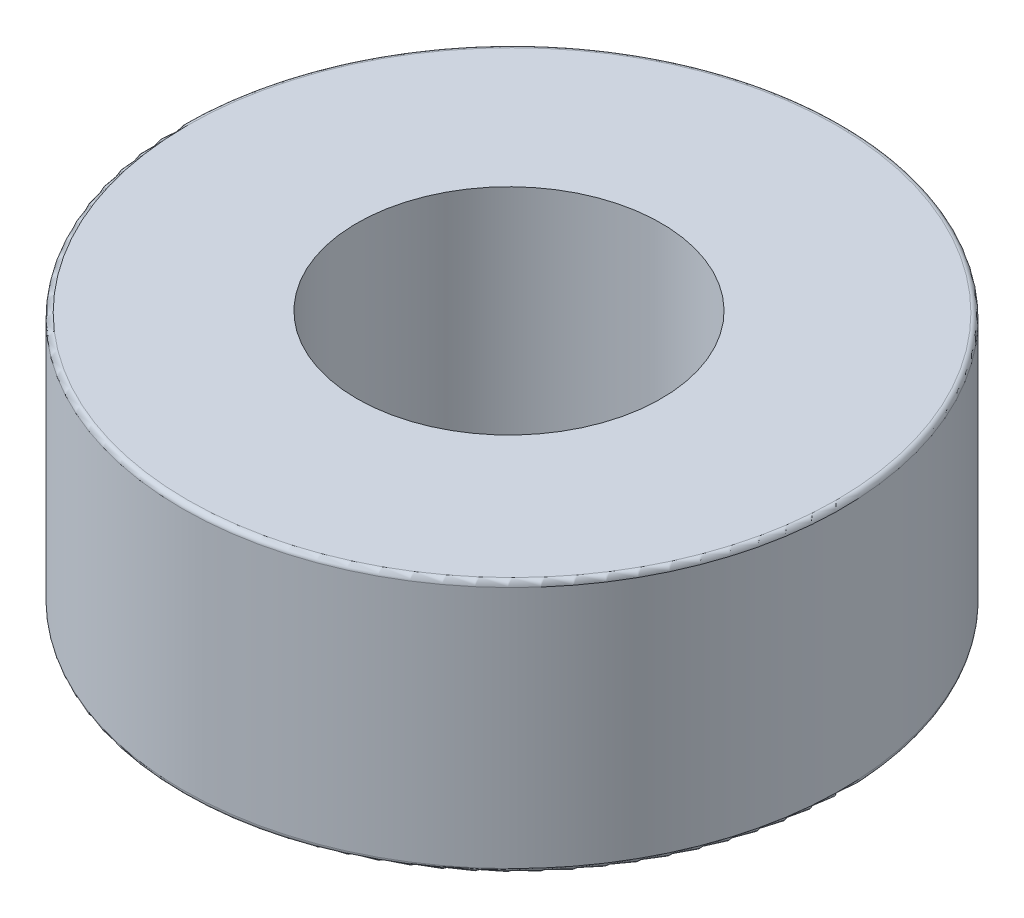
from build123d import *

# Parameters (mm, degrees)
SKETCH1_R           = 6.5
SKETCH1_R_2         = 3
BOSS_EXTRUDE1_DEPTH = 5
FILLET1_R           = 0.1


with BuildPart() as part:
    # Sketch1 → Boss-Extrude1 (new body)
    with BuildSketch(Plane(origin=(0, 0, 0), x_dir=(1, 0, 0), z_dir=(0, 1, 0))):
        with Locations((0.059793137, 0)):
            Circle(SKETCH1_R)
        Circle(SKETCH1_R_2, mode=Mode.SUBTRACT)
    extrude(amount=BOSS_EXTRUDE1_DEPTH)

    # Fillet1
    fillet1_edges = [part.edges().sort_by_distance(p)[0] for p in [
        (-6.440206863, 0, 0),
        (-6.440206863, 5, 0),
    ]]
    fillet(fillet1_edges, radius=FILLET1_R)


solid = part.part
